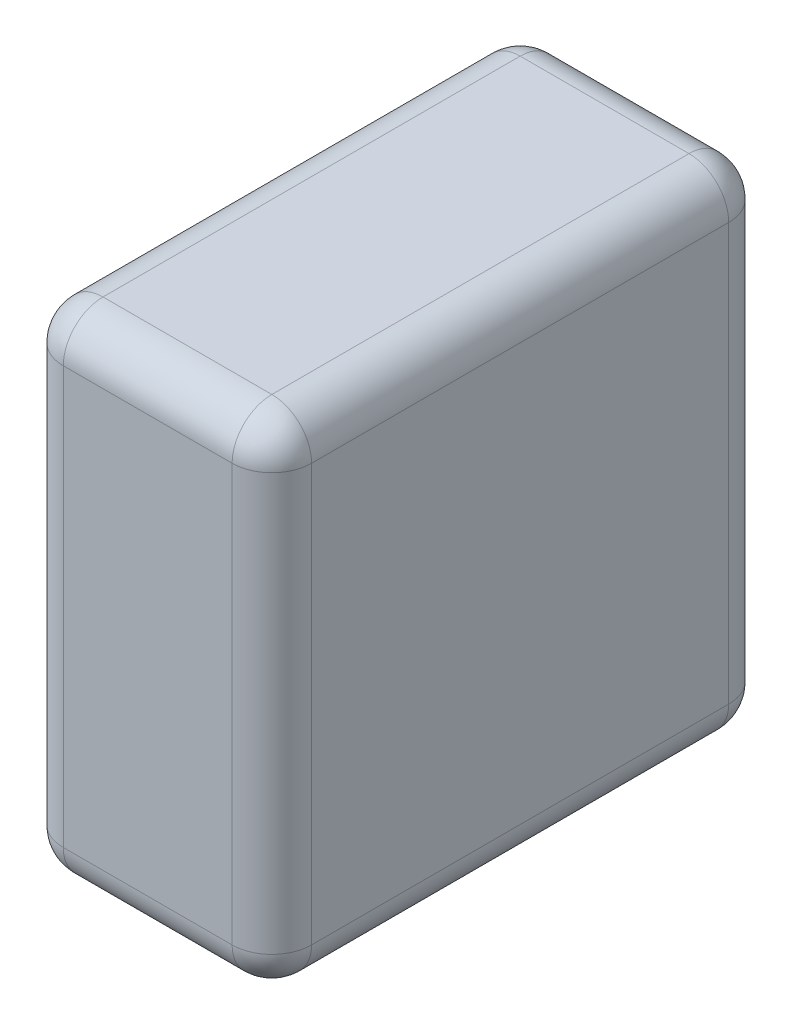
from build123d import *

# Parameters (mm, degrees)
SKETCH1_W      = 3.175
SKETCH1_H      = 3.175
EXTRUDE1_DEPTH = 0.79375
FILLET1_R      = 0.254


with BuildPart() as part:
    # Sketch1 → Extrude1 (new, symmetric)
    with BuildSketch(Plane(origin=(0, 0, 0), x_dir=(0, 0, -1), z_dir=(1, 0, 0))):
        Rectangle(SKETCH1_W, SKETCH1_H)
    extrude(amount=EXTRUDE1_DEPTH, both=True)

    # Fillet1
    fillet1_edges = [part.edges().sort_by_distance(p)[0] for p in [
        (0.79375, 0, -1.5875),
        (0.79375, 1.5875, 0),
        (0.79375, 0, 1.5875),
        (-0.79375, 1.5875, 0),
        (-0.79375, 0, -1.5875),
        (-0.79375, -1.5875, 0),
        (-0.79375, 0, 1.5875),
        (0.79375, -1.5875, 0),
        (0, 1.5875, 1.5875),
        (0, 1.5875, -1.5875),
        (0, -1.5875, -1.5875),
        (0, -1.5875, 1.5875),
    ]]
    fillet(fillet1_edges, radius=FILLET1_R)


solid = part.part
